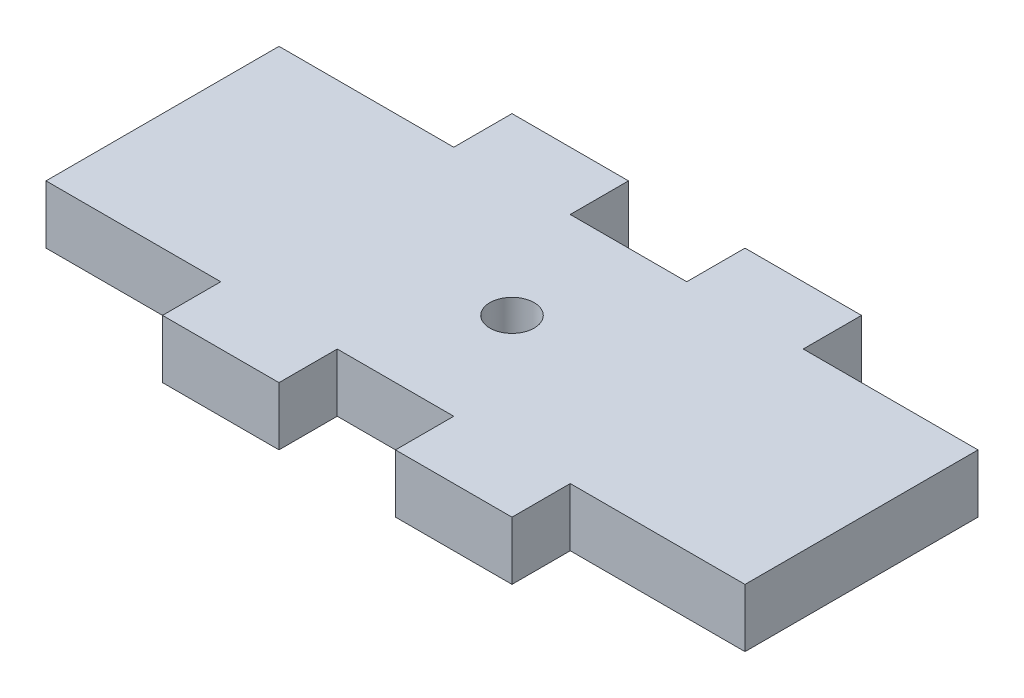
from build123d import *

# Parameters (mm, degrees)
SKETCH1_R           = 2.413
BOSS_EXTRUDE1_DEPTH = 6.35


with BuildPart() as part:
    # Sketch1 → Boss-Extrude1 (new body)
    with BuildSketch(Plane(origin=(0, 0, 0), x_dir=(1, 0, 0), z_dir=(0, 1, 0))):
        Polygon((-44.45, -12.7), (-31.75, -12.7), (-25.4, -12.7), (-25.4, -19.05), (-12.7, -19.05), (-12.7, -12.7), (0, -12.7), (0, -19.05), (12.7, -19.05), (12.7, -12.7), (31.75, -12.7), (31.75, 12.7), (12.7, 12.7), (12.7, 19.05), (0, 19.05), (0, 12.7), (-12.7, 12.7), (-12.7, 19.05), (-25.4, 19.05), (-25.4, 12.7), (-31.75, 12.7), (-44.45, 12.7), align=None)
        with Locations((-6.35, 0)):
            Circle(SKETCH1_R, mode=Mode.SUBTRACT)
    extrude(amount=BOSS_EXTRUDE1_DEPTH)


solid = part.part
